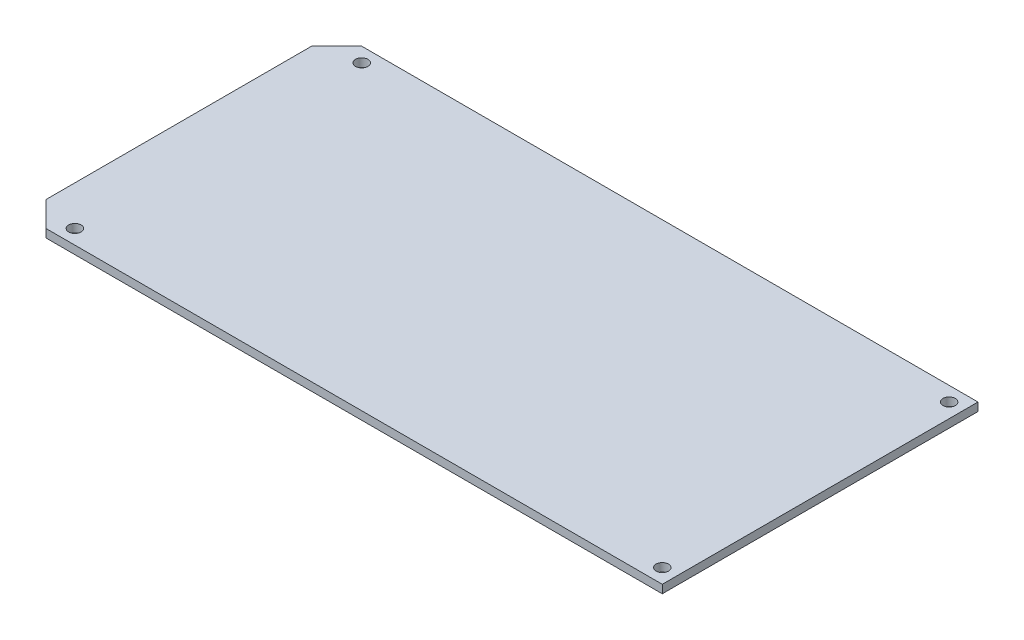
from build123d import *

# Parameters (mm, degrees)
SKETCH2_R           = 1.5
BOSS_EXTRUDE1_DEPTH = 2


with BuildPart() as part:
    # Sketch2 → Boss-Extrude1 (new body)
    with BuildSketch(Plane(origin=(0, 0, 0), x_dir=(1, 0, 0), z_dir=(0, 1, 0))):
        Polygon((-149.27, 76.47), (-155.34404725, 70.39595275), (-155.34404725, 6.07404725), (-149.27, 0), (0, 0), (0, 76.47), align=None)
        with Locations((-3.5, 72.97)):
            Circle(SKETCH2_R, mode=Mode.SUBTRACT)
        with Locations((-3.5, 3.5)):
            Circle(SKETCH2_R, mode=Mode.SUBTRACT)
        with Locations((-145.77, 72.97)):
            Circle(SKETCH2_R, mode=Mode.SUBTRACT)
        with Locations((-145.77, 3.5)):
            Circle(SKETCH2_R, mode=Mode.SUBTRACT)
    extrude(amount=BOSS_EXTRUDE1_DEPTH)


solid = part.part
